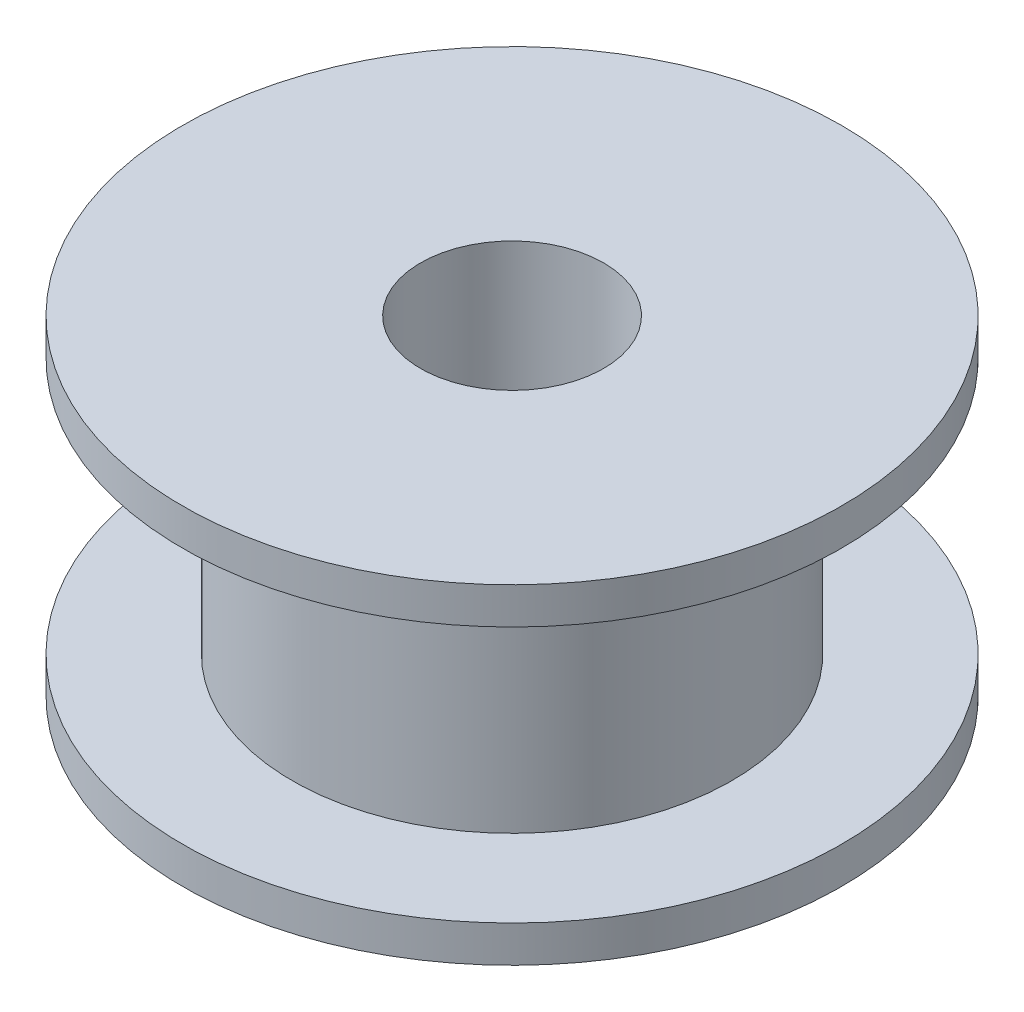
from build123d import *


with BuildPart() as part:
    # Sketch1 → Revolve1 (revolve)
    with BuildSketch(Plane.XY):
        Polygon((2.5, -4.5), (2.5, 4.5), (9, 4.5), (9, 3.5), (6, 3.5), (6, -3.5), (9, -3.5), (9, -4.5), align=None)
    revolve(axis=Axis((0, 0, 0), (0, 1, 0)))


solid = part.part
